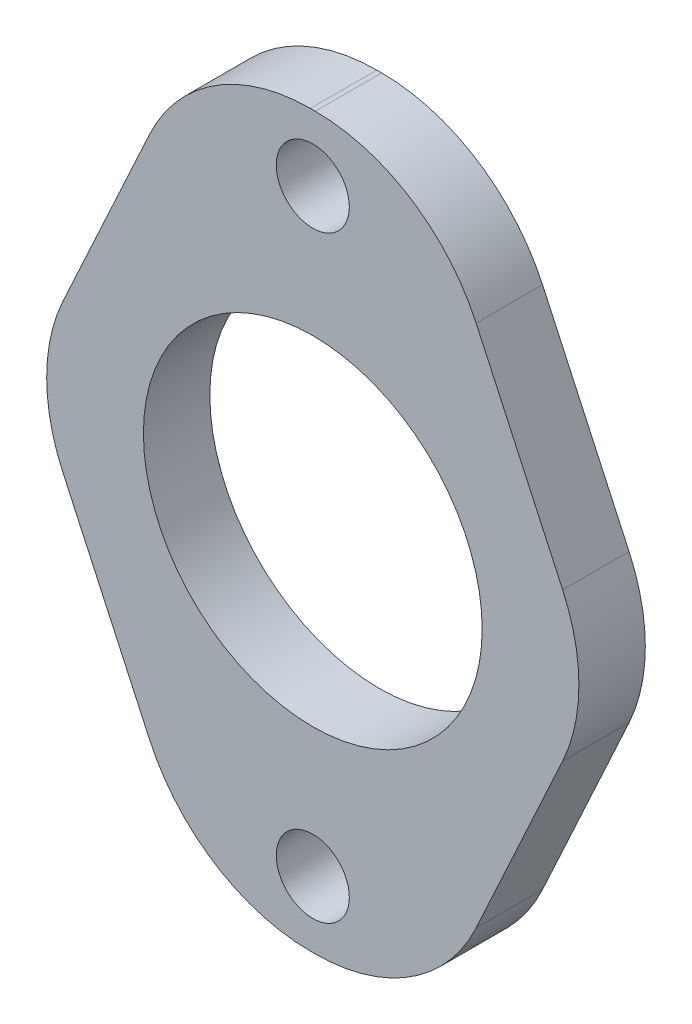
from build123d import *

# Parameters (mm, degrees)
ESBO_O1_R                = 7.65
ESBO_O1_R_2              = 1.65
RESSALTO_EXTRUS_O1_DEPTH = 3
FILETE1_R                = 8


with BuildPart() as part:
    # Esboço1 → Ressalto-extrusão1 (new body)
    with BuildSketch(Plane.XY):
        Polygon((-12.827454307, 0), (-5.233177242, 16.48), (5.233177242, 16.48), (12.827454307, 0), (5.233177242, -16.48), (-5.233177242, -16.48), align=None)
        Circle(ESBO_O1_R, mode=Mode.SUBTRACT)
        with Locations((0, -13.5)):
            Circle(ESBO_O1_R_2, mode=Mode.SUBTRACT)
        with Locations((0, 13.5)):
            Circle(ESBO_O1_R_2, mode=Mode.SUBTRACT)
    extrude(amount=RESSALTO_EXTRUS_O1_DEPTH)

    # Filete1
    filete1_edges = [part.edges().sort_by_distance(p)[0] for p in [
        (5.233177242, -16.48, 1.5),
        (-5.233177242, -16.48, 1.5),
        (-12.827454307, 0, 1.5),
        (-5.233177242, 16.48, 1.5),
        (5.233177242, 16.48, 1.5),
        (12.827454307, 0, 1.5),
    ]]
    fillet(filete1_edges, radius=FILETE1_R)


solid = part.part
